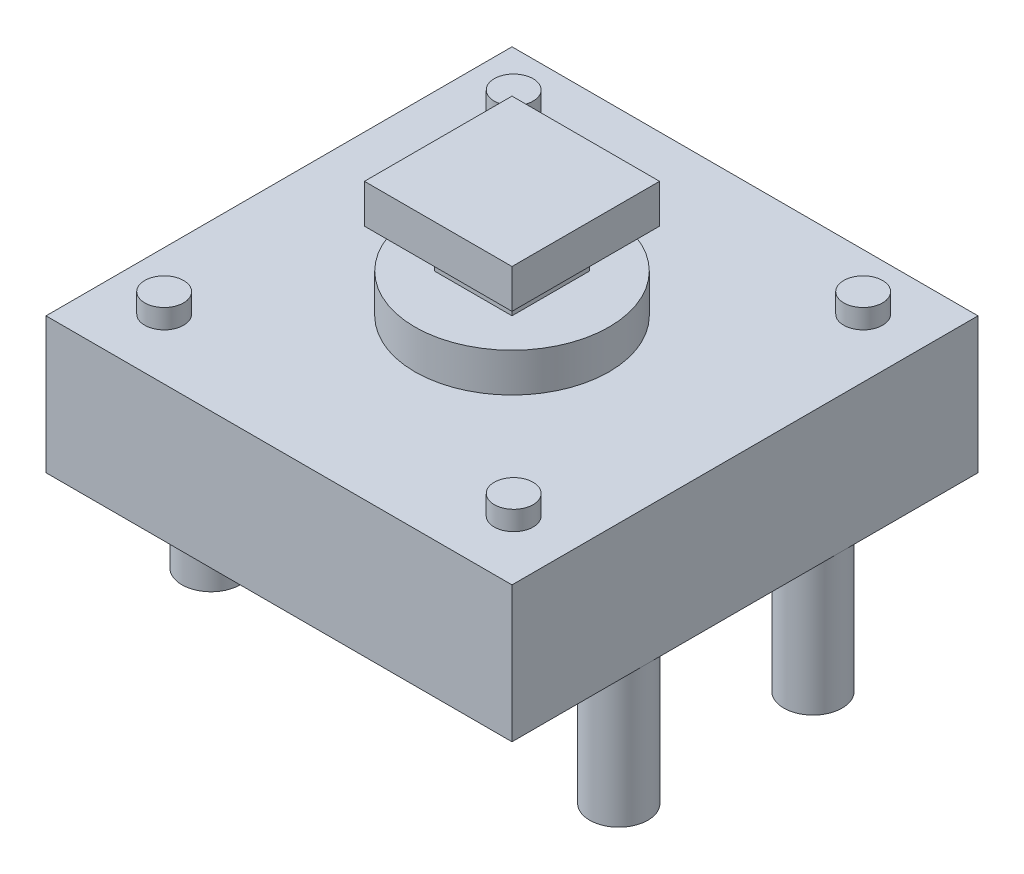
from build123d import *

# Parameters (mm, degrees)
SKETCH1_W           = 12
SKETCH1_H           = 12
BOSS_EXTRUDE1_DEPTH = 3.5
SKETCH2_R           = 2.5
BOSS_EXTRUDE2_DEPTH = 1
SKETCH3_R           = 0.5
BOSS_EXTRUDE3_DEPTH = 0.5
SKETCH4_W           = 2
SKETCH4_H           = 2
BOSS_EXTRUDE4_DEPTH = 1
SKETCH5_W           = 3.8
SKETCH5_H           = 3.8
BOSS_EXTRUDE5_DEPTH = 1
SKETCH6_R           = 0.75
BOSS_EXTRUDE6_DEPTH = 3.5


with BuildPart() as part:
    # Sketch1 → Boss-Extrude1 (new body)
    with BuildSketch(Plane(origin=(0, 0, 0), x_dir=(1, 0, 0), z_dir=(0, 1, 0))):
        Rectangle(SKETCH1_W, SKETCH1_H)
    extrude(amount=BOSS_EXTRUDE1_DEPTH)

    # Sketch2 → Boss-Extrude2 (add)
    with BuildSketch(Plane(origin=(0, 3.5, 0), x_dir=(1, 0, 0), z_dir=(0, 1, 0))):
        Circle(SKETCH2_R)
    extrude(amount=BOSS_EXTRUDE2_DEPTH)

    # Sketch3 → Boss-Extrude3 (add)
    with BuildSketch(Plane(origin=(0, 3.5, 0), x_dir=(1, 0, 0), z_dir=(0, 1, 0))):
        with Locations((-4.51726096, 4.56041336)):
            Circle(SKETCH3_R)
        with Locations((-4.51726096, -4.43958664)):
            Circle(SKETCH3_R)
        with Locations((4.48273904, -4.43958664)):
            Circle(SKETCH3_R)
        with Locations((4.48273904, 4.56041336)):
            Circle(SKETCH3_R)
    extrude(amount=BOSS_EXTRUDE3_DEPTH)

    # Sketch4 → Boss-Extrude4 (add)
    with BuildSketch(Plane(origin=(0, 4.5, 0), x_dir=(1, 0, 0), z_dir=(0, 1, 0))):
        Rectangle(SKETCH4_W, SKETCH4_H)
    extrude(amount=BOSS_EXTRUDE4_DEPTH)

    # Sketch5 → Boss-Extrude5 (add)
    with BuildSketch(Plane(origin=(0, 5.5, 0), x_dir=(1, 0, 0), z_dir=(0, 1, 0))):
        Rectangle(SKETCH5_W, SKETCH5_H)
    extrude(amount=BOSS_EXTRUDE5_DEPTH)

    # Sketch6 → Boss-Extrude6 (add)
    with BuildSketch(Plane.XZ):
        with Locations((-5.25, 2.5)):
            Circle(SKETCH6_R)
        with Locations((-5.25, -2.5)):
            Circle(SKETCH6_R)
        with Locations((5.25, -2.5)):
            Circle(SKETCH6_R)
        with Locations((5.25, 2.5)):
            Circle(SKETCH6_R)
    extrude(amount=BOSS_EXTRUDE6_DEPTH)


solid = part.part
